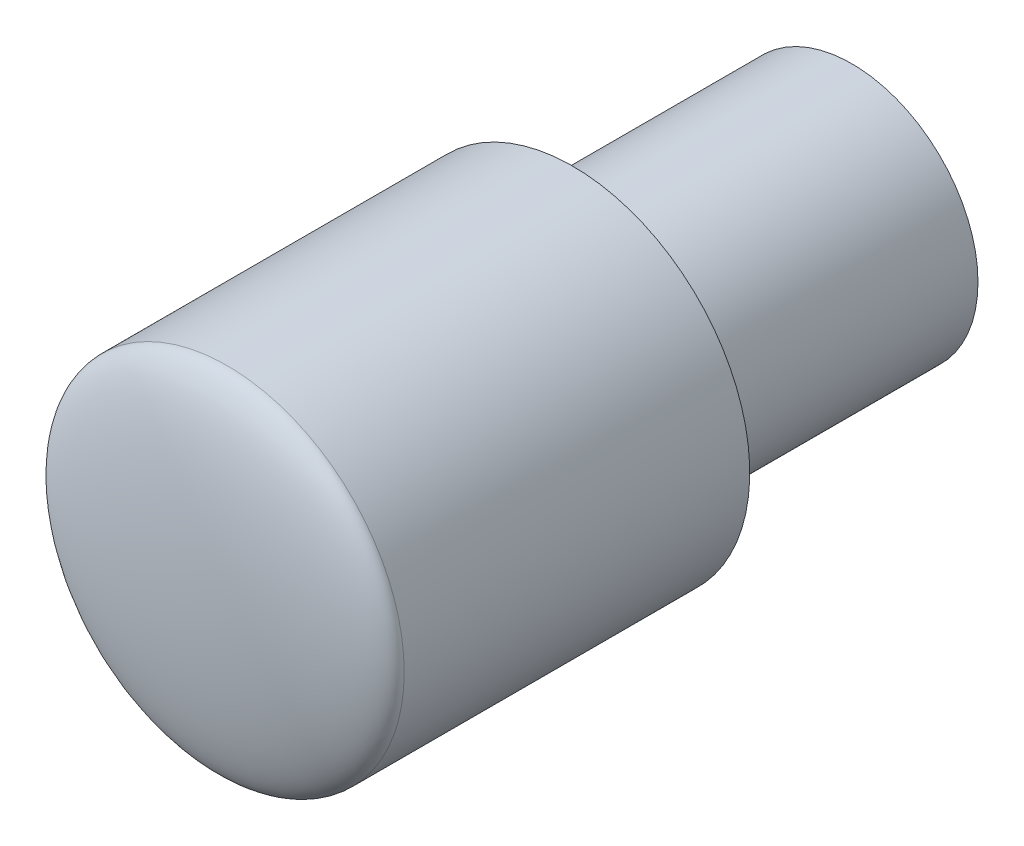
from build123d import *

# Parameters (mm, degrees)
SKETCH1_R          = 11.43413059
BASE_EXTRUDE_DEPTH = 40.360136162
DOME1_FACE_RADIUS  = 11.43413059
DOME1_HEIGHT       = 2.54
SKETCH2_OUTSIDE_W  = 35.612
SKETCH2_OUTSIDE_H  = 35.612
SKETCH2_OUTSIDE_R  = 8.14940086
CUT_EXTRUDE1_DEPTH = 18.034


with BuildPart() as part:
    # Sketch1 → Base-Extrude (new body)
    with BuildSketch(Plane.XY):
        with Locations((-45.925033829, 18.948035519)):
            Circle(SKETCH1_R)
    extrude(amount=BASE_EXTRUDE_DEPTH)

    # Dome1: an elliptical dome of height H over a round flat face of radius A is half a spheroid: the quarter ellipse of half axes A and H revolved about the face's axis
    with BuildSketch(Plane((-45.925033829, 18.948035519, 40.360136162), x_dir=(0, 1, 0), z_dir=(1, 0, 0)), mode=Mode.PRIVATE) as dome1_quarter:
        Ellipse(DOME1_FACE_RADIUS, DOME1_HEIGHT)
        Rectangle(DOME1_FACE_RADIUS, DOME1_HEIGHT, align=(Align.MIN, Align.MIN), mode=Mode.INTERSECT)
    revolve(dome1_quarter.sketch, axis=Axis((-45.925033829, 18.948035519, 40.360136162), (0, 0, 1)))

    # Sketch2 outside → Cut-Extrude1 (cut)
    with BuildSketch(Plane(origin=(0, 0, 0), x_dir=(-1, 0, 0), z_dir=(0, 0, -1))):
        with Locations((45.925, 18.948)):
            Rectangle(SKETCH2_OUTSIDE_W, SKETCH2_OUTSIDE_H)
        with Locations((45.925033829, 18.948035519)):
            Circle(SKETCH2_OUTSIDE_R, mode=Mode.SUBTRACT)
    extrude(amount=-CUT_EXTRUDE1_DEPTH, mode=Mode.SUBTRACT)


solid = part.part
